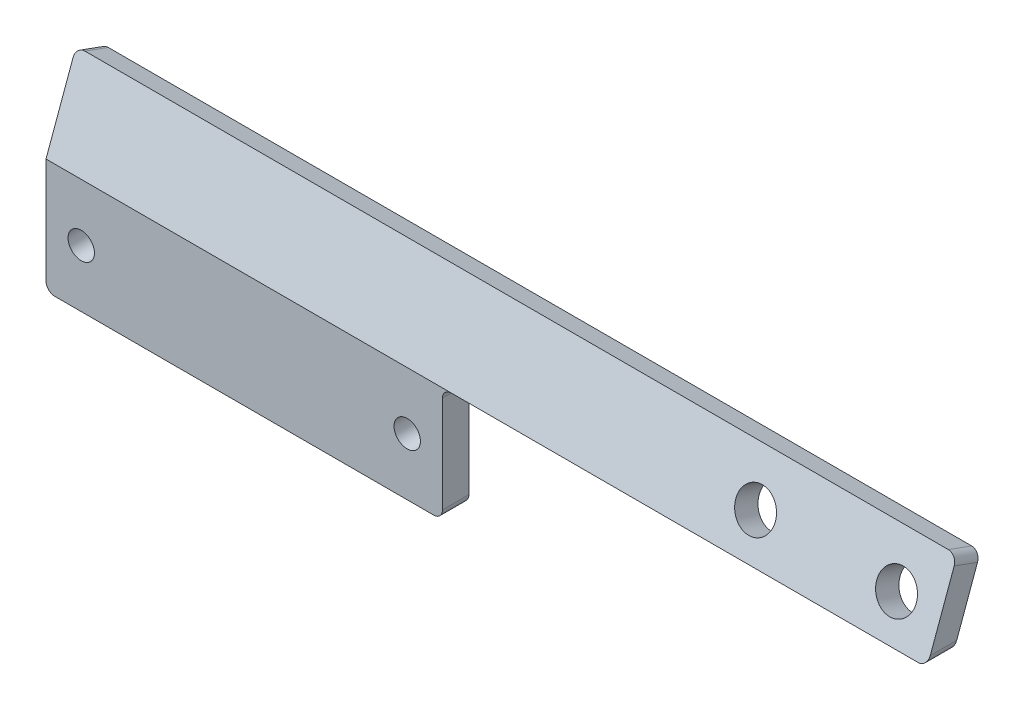
from build123d import *

# Parameters (mm, degrees)
ESQUISSE1_W                = 45
ESQUISSE1_H                = 13
BOSS_EXTRU_1_DEPTH         = 3
ESQUISSE2_R                = 1.5
ENL_V_MAT_EXTRU_1_DEPTH    = 4
BOSS_EXTRU_3_DEPTH         = 100
CONG_1_R                   = 1
ESQUISSE12_R               = 2.25
ENL_V_MAT_EXTRU_3_DEPTH    = 11.149508308
R_P_TITION_LIN_AIRE1_COUNT = 2
R_P_TITION_LIN_AIRE1_PITCH = 16


with BuildPart() as part:
    # Esquisse1 → Boss.-Extru.1 (new body)
    with BuildSketch(Plane.XY):
        with Locations((22.5, 6.5)):
            Rectangle(ESQUISSE1_W, ESQUISSE1_H)
    extrude(amount=BOSS_EXTRU_1_DEPTH)

    # Esquisse2 → Enl_v. mat.-Extru.1 (cut, through all)
    with BuildSketch(Plane.XY.offset(3)):
        with Locations((41, 6.5)):
            Circle(ESQUISSE2_R)
    enl_v_mat_extru_1 = extrude(amount=-ENL_V_MAT_EXTRU_1_DEPTH, mode=Mode.SUBTRACT)

    # Sym_trie1: Enl_v. mat.-Extru.1 across plane
    add(enl_v_mat_extru_1.mirror(Plane.ZY.offset(-22.5)), mode=Mode.SUBTRACT)

    # Esquisse8 → Boss.-Extru.3 (add)
    with BuildSketch(Plane.ZY):
        Polygon((0, 13), (-3.069268098, 21.432744793), (-0.420201433, 22.396926208), (3, 13), align=None)
    extrude(amount=-BOSS_EXTRU_3_DEPTH)

    # Cong_1
    cong_1_edges = [part.edges().sort_by_distance(p)[0] for p in [
        (45, 0, 1.5),
        (0, 0, 1.5),
        (45, 13, 1.5),
        (100, 13, 1.5),
        (100, 21.914835501, -1.744734766),
        (0, 21.914835501, -1.744734766),
    ]]
    fillet(cong_1_edges, radius=CONG_1_R)

    # Esquisse12 → Enl_v. mat.-Extru.3 (cut, through all)
    with BuildSketch(Plane(origin=(0, 2.484892534, 6.827186128), x_dir=(1, 0, 0), z_dir=(0, 0.342020143, 0.939692621))):
        with Locations((95, 15.68994364)):
            Circle(ESQUISSE12_R)
    enl_v_mat_extru_3 = extrude(amount=-ENL_V_MAT_EXTRU_3_DEPTH, mode=Mode.SUBTRACT)

    # R_p_tition lin_aire1: Enl_v. mat.-Extru.3 ×2
    with Locations(*[(-i * R_P_TITION_LIN_AIRE1_PITCH, 0, 0) for i in range(1, R_P_TITION_LIN_AIRE1_COUNT)]):
        add(enl_v_mat_extru_3, mode=Mode.SUBTRACT)


solid = part.part
